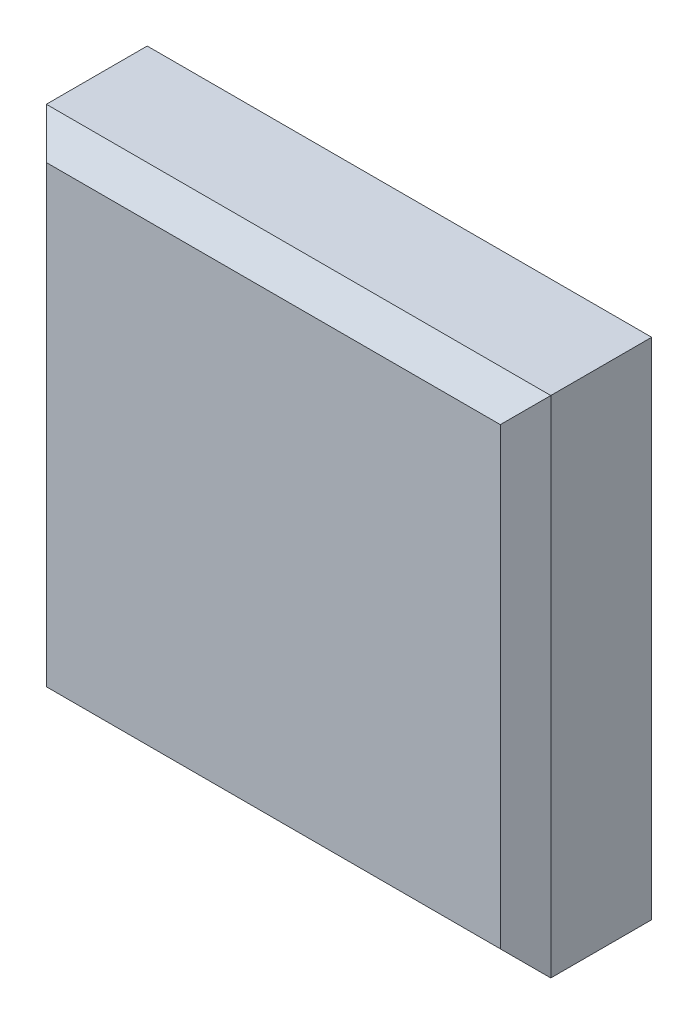
from build123d import *

# Parameters (mm, degrees)
ESQUISSE1_W        = 20
ESQUISSE1_H        = 20
BOSS_EXTRU_1_DEPTH = 5
CHANFREIN1_SIZE    = 1


with BuildPart() as part:
    # Esquisse1 → Boss.-Extru.1 (new body)
    with BuildSketch(Plane.XY):
        with Locations((10, -10)):
            Rectangle(ESQUISSE1_W, ESQUISSE1_H)
    extrude(amount=BOSS_EXTRU_1_DEPTH)

    # Chanfrein1
    chanfrein1_edges = [part.edges().sort_by_distance(p)[0] for p in [
        (20, -10, 5),
        (10, 0, 5),
        (0, -10, 5),
        (10, -20, 5),
    ]]
    chamfer(chanfrein1_edges, length=CHANFREIN1_SIZE)


solid = part.part
